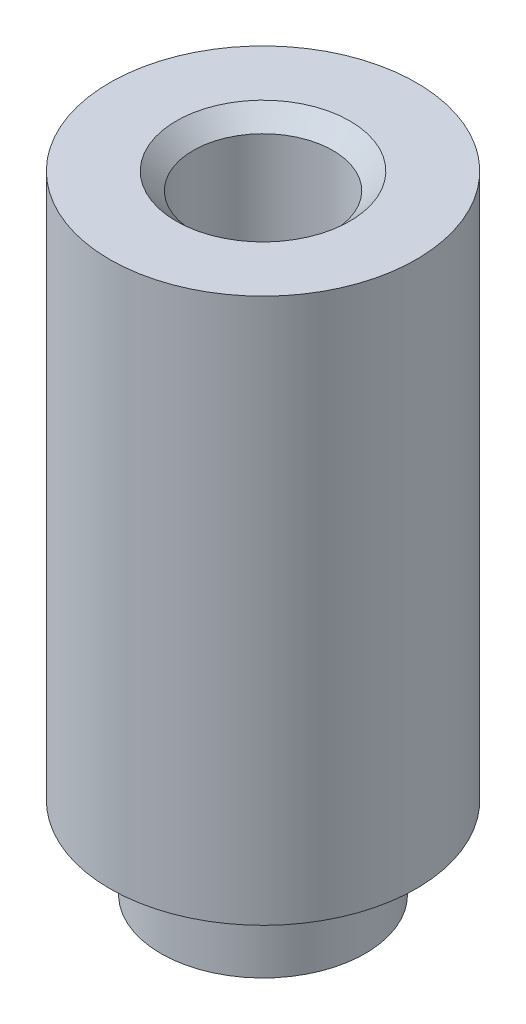
from build123d import *

# Parameters (mm, degrees)
SKETCH_1_R                     = 1.5
EXTRUDE_1_DEPTH                = 1.2
SKETCH_2_R                     = 2.25
EXTRUDE_2_DEPTH                = 8
HOLE_WIZARD_M2_5_1_D           = 2.05
HOLE_WIZARD_M2_5_1_CSINK_D     = 2.55
HOLE_WIZARD_M2_5_1_CSINK_ANGLE = 90


with BuildPart() as part:
    # 草图1 → 凸台-拉伸1 (new body)
    with BuildSketch(Plane(origin=(0, 0, 0), x_dir=(1, 0, 0), z_dir=(0, 1, 0))):
        Circle(SKETCH_1_R)
    extrude(amount=EXTRUDE_1_DEPTH)

    # 草图2 → 凸台-拉伸2 (add)
    with BuildSketch(Plane(origin=(0, 1.2, 0), x_dir=(1, 0, 0), z_dir=(0, 1, 0))):
        Circle(SKETCH_2_R)
    extrude(amount=EXTRUDE_2_DEPTH)

    # M2.5 螺纹孔1 (through all)
    with Locations(Plane(origin=(0, 9.2, 0), x_dir=(1, 0, 0), z_dir=(0, 1, 0))):
        with Locations((0, 0)):
            CounterSinkHole(HOLE_WIZARD_M2_5_1_D / 2, HOLE_WIZARD_M2_5_1_CSINK_D / 2, counter_sink_angle=HOLE_WIZARD_M2_5_1_CSINK_ANGLE)


solid = part.part
